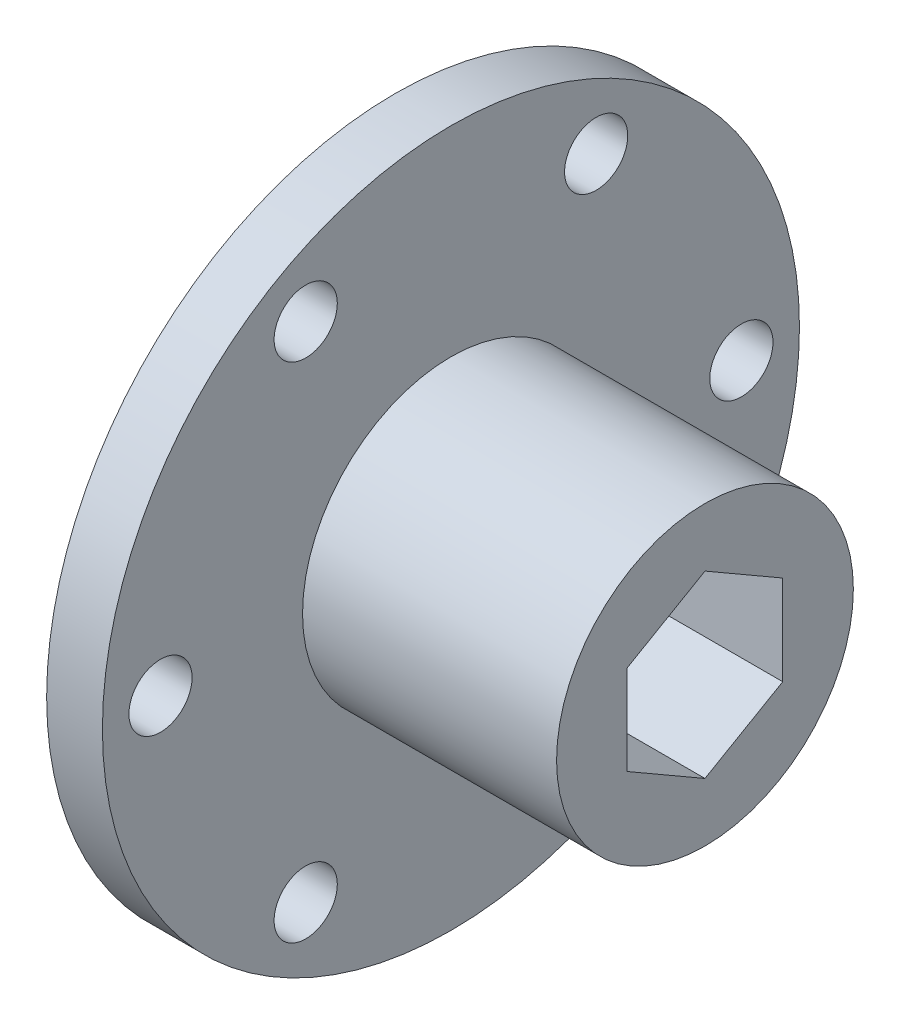
from build123d import *

# Parameters (mm, degrees)
SKETCH1_W           = 4.572
SKETCH1_H           = 28.575
SKETCH2_R           = 12.1666
BOSS_EXTRUDE1_DEPTH = 20.828
CUT_EXTRUDE1_DEPTH  = 26.4
HOLE1_D             = 5.1816
HOLE1_DEPTH         = 4.572
CIRPATTERN1_COUNT   = 6


with BuildPart() as part:
    # Sketch1 → Revolve1 (revolve)
    with BuildSketch(Plane(origin=(0, 0, 0), x_dir=(-1, 0, 0), z_dir=(0, 0, -1))):
        with Locations((15.321066246, 14.2875)):
            Rectangle(SKETCH1_W, SKETCH1_H)
    revolve(axis=Axis((-13.035066246, 0, 0), (-1, 0, 0)))

    # Sketch2 → Boss-Extrude1 (add)
    with BuildSketch(Plane(origin=(-13.035066246, 0, 0), x_dir=(0, 0, -1), z_dir=(1, 0, 0))):
        Circle(SKETCH2_R)
    extrude(amount=BOSS_EXTRUDE1_DEPTH)

    # Sketch3 → Cut-Extrude1 (cut, through all)
    with BuildSketch(Plane(origin=(7.792933754, 0, 0), x_dir=(0, 0, -1), z_dir=(1, 0, 0))):
        Polygon((0, -7.361697812), (6.3754, -3.680858906), (6.3754, 3.680818906), (0, 7.361657812), (-6.3754, 3.680818906), (-6.3754, -3.680858906), align=None)
    extrude(amount=-CUT_EXTRUDE1_DEPTH, mode=Mode.SUBTRACT)

    # Hole1
    with Locations(Plane(origin=(-13.035066246, 0, 0), x_dir=(0, 0, -1), z_dir=(1, 0, 0))):
        with Locations((-23.8125, 0)):
            hole1 = Hole(HOLE1_D / 2, depth=HOLE1_DEPTH)

    # CirPattern1: Hole1 ×6 about axis
    cirpattern1_axis = Axis((0, 0, 0), (1, 0, 0))
    for i in range(1, CIRPATTERN1_COUNT):
        add(hole1.rotate(cirpattern1_axis, i * 360 / CIRPATTERN1_COUNT), mode=Mode.SUBTRACT)


solid = part.part
